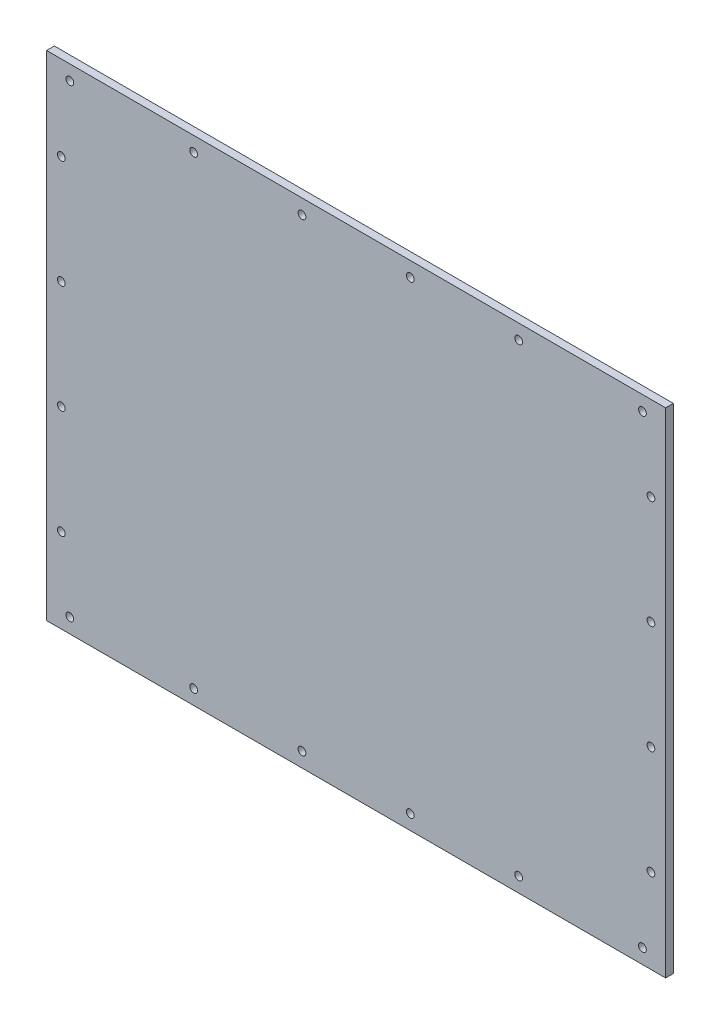
from build123d import *

# Parameters (mm, degrees)
SKETCH1_W           = 400
SKETCH1_H           = 319.05
BOSS_EXTRUDE1_DEPTH = 5
SKETCH2_R           = 2.5
CUT_EXTRUDE1_DEPTH  = 10
SKETCH3_R           = 2.5
CUT_EXTRUDE2_DEPTH  = 6


with BuildPart() as part:
    # Sketch1 → Boss-Extrude1 (new body)
    with BuildSketch(Plane.XY):
        with Locations((200, 159.525)):
            Rectangle(SKETCH1_W, SKETCH1_H)
    extrude(amount=BOSS_EXTRUDE1_DEPTH)

    # Sketch2 → Cut-Extrude1 (cut)
    with BuildSketch(Plane.XY.offset(5)):
        with Locations((15, 9.5)):
            Circle(SKETCH2_R)
        with Locations((95, 9.5)):
            Circle(SKETCH2_R)
        with Locations((165, 9.5)):
            Circle(SKETCH2_R)
        with Locations((235, 9.5)):
            Circle(SKETCH2_R)
        with Locations((305, 9.5)):
            Circle(SKETCH2_R)
        with Locations((385, 9.5)):
            Circle(SKETCH2_R)
        with Locations((385, 309.55)):
            Circle(SKETCH2_R)
        with Locations((305, 309.55)):
            Circle(SKETCH2_R)
        with Locations((235, 309.55)):
            Circle(SKETCH2_R)
        with Locations((165, 309.55)):
            Circle(SKETCH2_R)
        with Locations((95, 309.55)):
            Circle(SKETCH2_R)
        with Locations((15, 309.55)):
            Circle(SKETCH2_R)
    extrude(amount=-CUT_EXTRUDE1_DEPTH, mode=Mode.SUBTRACT)

    # Sketch3 → Cut-Extrude2 (cut, through all)
    with BuildSketch(Plane.XY.offset(5)):
        with Locations((9.5, 264.525)):
            Circle(SKETCH3_R)
        with Locations((9.5, 194.525)):
            Circle(SKETCH3_R)
        with Locations((9.5, 124.525)):
            Circle(SKETCH3_R)
        with Locations((9.5, 54.525)):
            Circle(SKETCH3_R)
        with Locations((390.5, 54.525)):
            Circle(SKETCH3_R)
        with Locations((390.5, 124.525)):
            Circle(SKETCH3_R)
        with Locations((390.5, 194.525)):
            Circle(SKETCH3_R)
        with Locations((390.5, 264.525)):
            Circle(SKETCH3_R)
    extrude(amount=-CUT_EXTRUDE2_DEPTH, mode=Mode.SUBTRACT)


solid = part.part
